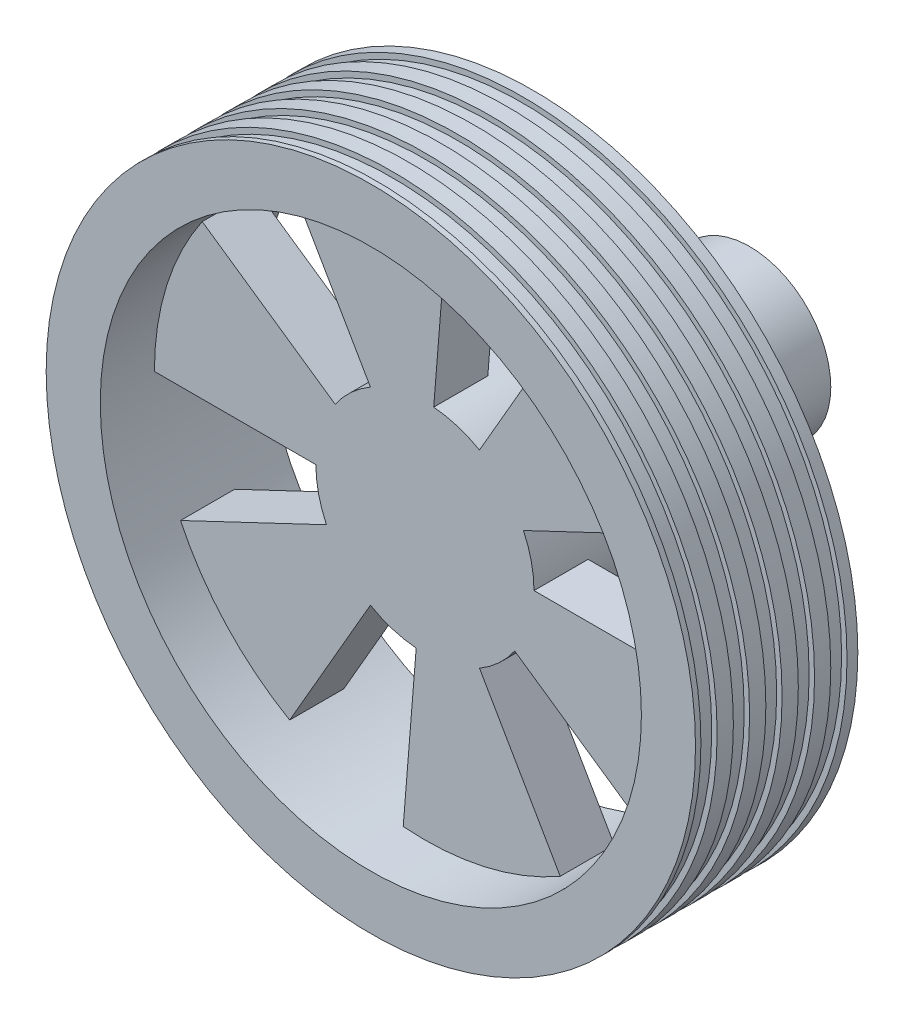
from build123d import *

# Parameters (mm, degrees)
SKETCH1_R           = 30
BOSS_EXTRUDE1_DEPTH = 15
SKETCH2_R           = 7.5
SKETCH2_R_2         = 1
BOSS_EXTRUDE2_DEPTH = 20
SKETCH4_R           = 3.175
CUT_EXTRUDE1_DEPTH  = 1.6
SKETCH5_W           = 2
SKETCH5_H           = 2.576429586
SKETCH5_W_2         = 1.5
SKETCH5_H_2         = 1
SKETCH5_4_W         = 1.5
SKETCH5_4_H         = 1
CUT_EXTRUDE2_START  = -5
SKETCH6_R           = 25
SKETCH6_R_2         = 10.076429586
CUT_EXTRUDE2_DEPTH  = 5
SKETCH7_R           = 25
CUT_EXTRUDE3_DEPTH  = 5
CUT_EXTRUDE4_START  = -5
CUT_EXTRUDE4_DEPTH  = 5
SKETCH9_W           = 1.5
SKETCH9_H           = 0.5


with BuildPart() as part:
    # Sketch1 → Boss-Extrude1 (new body)
    with BuildSketch(Plane.XY):
        Circle(SKETCH1_R)
    extrude(amount=BOSS_EXTRUDE1_DEPTH)

    # Sketch2 → Boss-Extrude2 (add)
    with BuildSketch(Plane.XY):
        Circle(SKETCH2_R)
        Circle(SKETCH2_R_2, mode=Mode.SUBTRACT)
    extrude(amount=-BOSS_EXTRUDE2_DEPTH)

    # Sketch4 → Cut-Extrude1 (cut)
    with BuildSketch(Plane(origin=(0, 0, -20), x_dir=(-1, 0, 0), z_dir=(0, 0, -1))):
        Circle(SKETCH4_R)
    extrude(amount=-CUT_EXTRUDE1_DEPTH, mode=Mode.SUBTRACT)

    # Sketch5 → Revolve2 (revolve)
    with BuildSketch(Plane(origin=(0, 0, 0), x_dir=(0, 0, -1), z_dir=(1, 0, 0))):
        with Locations((1, 8.788214793)):
            Rectangle(SKETCH5_W, SKETCH5_H)
        with Locations((12.75, 7)):
            Rectangle(SKETCH5_W_2, SKETCH5_H_2)
    revolve(axis=Axis((0, 0, -21.75), (0, 0, 1)))

    # Sketch5_4 → Cut-Revolve1 (revolve, cut)
    with BuildSketch(Plane(origin=(0, 0, 0), x_dir=(0, 0, -1), z_dir=(1, 0, 0))):
        with Locations((12.75, 7)):
            Rectangle(SKETCH5_4_W, SKETCH5_4_H)
    revolve(axis=Axis((0, 0, -21.75), (0, 0, 1)), mode=Mode.SUBTRACT)

    # Sketch6 → Cut-Extrude2 (cut)
    with BuildSketch(Plane(origin=(0, 0, 0), x_dir=(-1, 0, 0), z_dir=(0, 0, -1)).offset(CUT_EXTRUDE2_START)):
        Circle(SKETCH6_R)
        Circle(SKETCH6_R_2, mode=Mode.SUBTRACT)
    extrude(amount=CUT_EXTRUDE2_DEPTH, mode=Mode.SUBTRACT)

    # Sketch7 → Cut-Extrude3 (cut)
    with BuildSketch(Plane.XY.offset(15)):
        Circle(SKETCH7_R)
    extrude(amount=-CUT_EXTRUDE3_DEPTH, mode=Mode.SUBTRACT)

    # Sketch8 → Cut-Extrude4 (cut)
    with BuildSketch(Plane(origin=(0, 0, 5), x_dir=(-1, 0, 0), z_dir=(0, 0, -1)).offset(CUT_EXTRUDE4_START)):
        with BuildLine():
            Line((-10.076429586, 0), (-25, 0))
            ThreePointArc((-25, 0), (-24.388602599, 5.495094475), (-22.584314937, 10.721414032))
            Line((-22.584314937, 10.721414032), (-9.102770368, 4.321342942))
            ThreePointArc((-9.102770368, 4.321342942), (-9.830001471, 2.214837302), (-10.076429586, 0))
        make_face()
        with BuildLine():
            Line((-2.007140552, 24.919297478), (-0.808992418, 10.043901854))
            ThreePointArc((-0.808992418, 10.043901854), (-2.996895367, 9.620449644), (-5.038214793, 8.726444001))
            Line((-5.038214793, 8.726444001), (-12.5, 21.650635095))
            ThreePointArc((-12.5, 21.650635095), (-7.435409888, 23.868696651), (-2.007140552, 24.919297478))
        make_face()
        with BuildLine():
            Line((20.577174384, 14.197883446), (8.29377795, 5.722558913))
            ThreePointArc((8.29377795, 5.722558913), (6.833106104, 7.405612342), (5.038214793, 8.726444001))
            Line((5.038214793, 8.726444001), (12.5, 21.650635095))
            ThreePointArc((12.5, 21.650635095), (16.953192711, 18.373602176), (20.577174384, 14.197883446))
        make_face()
        with BuildLine():
            Line((22.584314937, -10.721414032), (9.102770368, -4.321342942))
            ThreePointArc((9.102770368, -4.321342942), (9.830001471, -2.214837302), (10.076429586, 0))
            Line((10.076429586, 0), (25, 0))
            ThreePointArc((25, 0), (24.388602599, -5.495094475), (22.584314937, -10.721414032))
        make_face()
        with BuildLine():
            Line((2.007140552, -24.919297478), (0.808992418, -10.043901854))
            ThreePointArc((0.808992418, -10.043901854), (2.996895367, -9.620449644), (5.038214793, -8.726444001))
            Line((5.038214793, -8.726444001), (12.5, -21.650635095))
            ThreePointArc((12.5, -21.650635095), (7.435409888, -23.868696651), (2.007140552, -24.919297478))
        make_face()
        with BuildLine():
            Line((-20.577174384, -14.197883446), (-8.29377795, -5.722558913))
            ThreePointArc((-8.29377795, -5.722558913), (-6.833106104, -7.405612342), (-5.038214793, -8.726444001))
            Line((-5.038214793, -8.726444001), (-12.5, -21.650635095))
            ThreePointArc((-12.5, -21.650635095), (-16.953192711, -18.373602176), (-20.577174384, -14.197883446))
        make_face()
    extrude(amount=CUT_EXTRUDE4_DEPTH, mode=Mode.SUBTRACT)

    # Sketch9 → Cut-Revolve2 (revolve, cut)
    with BuildSketch(Plane(origin=(0, 0, 0), x_dir=(0, 0, -1), z_dir=(1, 0, 0))):
        with Locations((-1.75, 29.75)):
            Rectangle(SKETCH9_W, SKETCH9_H)
        with Locations((-4.75, 29.75)):
            Rectangle(SKETCH9_W, SKETCH9_H)
        with Locations((-7.75, 29.75)):
            Rectangle(SKETCH9_W, SKETCH9_H)
        with Locations((-10.75, 29.75)):
            Rectangle(SKETCH9_W, SKETCH9_H)
        with Locations((-13.75, 29.75)):
            Rectangle(SKETCH9_W, SKETCH9_H)
    revolve(axis=Axis((0, 0, -21.75), (0, 0, 1)), mode=Mode.SUBTRACT)


solid = part.part
